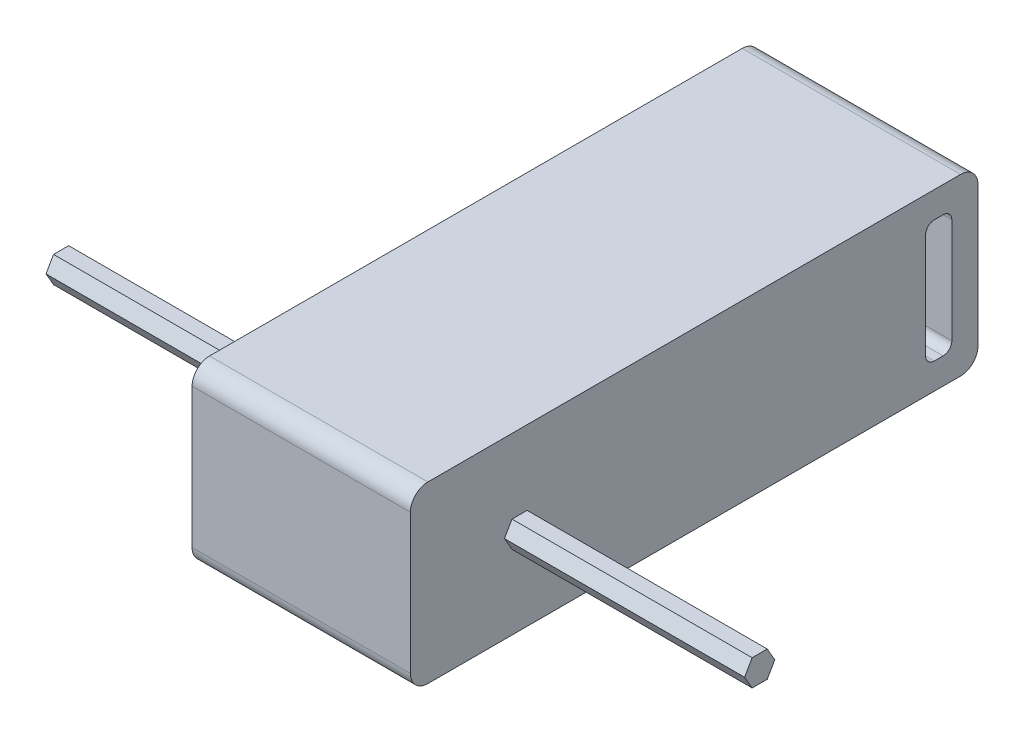
from build123d import *

# Parameters (mm, degrees)
SKETCH_1_W          = 65
SKETCH_1_H          = 20
EXTRUDE_1_DEPTH     = 25
FILLET_1_R          = 2
FILLET_2_R          = 2
FILLET_3_R          = 2
FILLET_4_R          = 2
EXTRUDE_2_DEPTH     = 40
CUT_EXTRUDE_1_DEPTH = 5


with BuildPart() as part:
    # 草图1 → 凸台-拉伸1 (new body)
    with BuildSketch(Plane(origin=(0, 0, 0), x_dir=(0, 0, -1), z_dir=(1, 0, 0))):
        with Locations((0, 10)):
            Rectangle(SKETCH_1_W, SKETCH_1_H)
    extrude(amount=EXTRUDE_1_DEPTH)

    # 圆角1
    fillet_1_edges = [part.edges().sort_by_distance(p)[0] for p in [
        (12.5, 20, 32.5),
    ]]
    fillet(fillet_1_edges, radius=FILLET_1_R)

    # 圆角2
    fillet_2_edges = [part.edges().sort_by_distance(p)[0] for p in [
        (12.5, 0, 32.5),
    ]]
    fillet(fillet_2_edges, radius=FILLET_2_R)

    # 圆角3
    fillet_3_edges = [part.edges().sort_by_distance(p)[0] for p in [
        (12.5, 20, -32.5),
    ]]
    fillet(fillet_3_edges, radius=FILLET_3_R)

    # 圆角4
    fillet_4_edges = [part.edges().sort_by_distance(p)[0] for p in [
        (12.5, 0, -32.5),
    ]]
    fillet(fillet_4_edges, radius=FILLET_4_R)

    # 草图3 → 凸台-拉伸2 (add, symmetric)
    with BuildSketch(Plane.ZY.offset(-12.5)):
        Polygon((18.267949192, 10), (19.133974596, 8.5), (20.866025404, 8.5), (21.732050808, 10), (20.866025404, 11.5), (19.133974596, 11.5), align=None)
    extrude(amount=EXTRUDE_2_DEPTH, both=True)

    # 草图4 → 切除-拉伸1 (cut)
    with BuildSketch(Plane.ZY.offset(-25)):
        with BuildLine():
            Line((-29.5, 4), (-29.5, 16))
            ThreePointArc((-29.5, 16), (-29.207106781, 16.707106781), (-28.5, 17))
            Line((-28.5, 17), (-27.5, 17))
            ThreePointArc((-27.5, 17), (-26.792893219, 16.707106781), (-26.5, 16))
            Line((-26.5, 16), (-26.5, 4))
            ThreePointArc((-26.5, 4), (-26.792893219, 3.292893219), (-27.5, 3))
            Line((-27.5, 3), (-28.5, 3))
            ThreePointArc((-28.5, 3), (-29.207106781, 3.292893219), (-29.5, 4))
        make_face()
    cut_extrude_1 = extrude(amount=CUT_EXTRUDE_1_DEPTH, mode=Mode.SUBTRACT)

    # 镜向1: 切除-拉伸1 across plane
    add(cut_extrude_1.mirror(Plane.ZY.offset(-12.5)), mode=Mode.SUBTRACT)


solid = part.part
